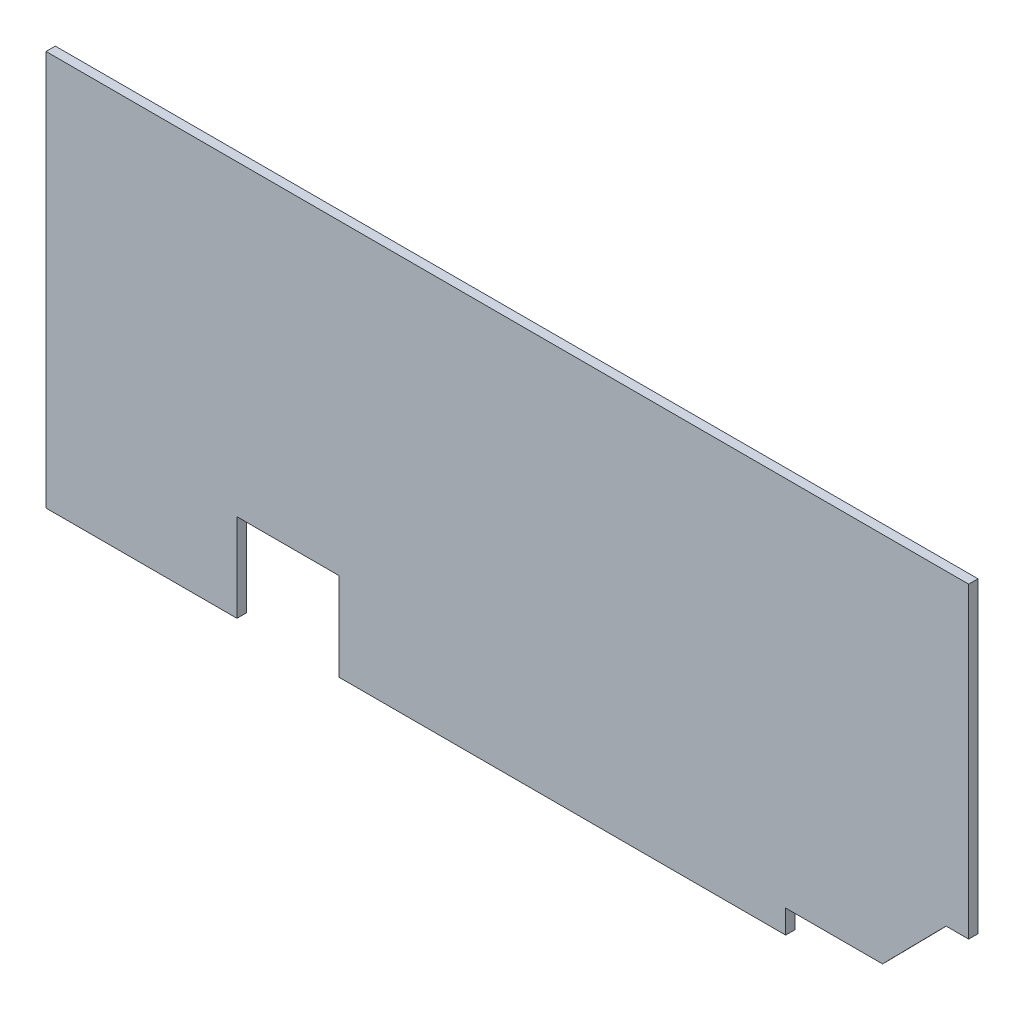
from build123d import *

# Parameters (mm, degrees)
BOSS_EXTRUDE1_DEPTH = 3.175


with BuildPart() as part:
    # Sketch1 → Boss-Extrude1 (new body)
    with BuildSketch(Plane.XY):
        Polygon((-268.400790405, 107.434120248), (46.049622496, 107.434120248), (46.049622496, 2.659120248), (38.341653517, 2.659120248), (16.679209595, -19.340879752), (-16.320790405, -19.340879752), (-16.320790405, -27.340879752), (-168.566368426, -27.340879752), (-168.566368426, 2.659120248), (-203.320790346, 2.659120248), (-203.320790346, -27.340879752), (-268.400790405, -27.340879752), align=None)
    extrude(amount=BOSS_EXTRUDE1_DEPTH)


solid = part.part
